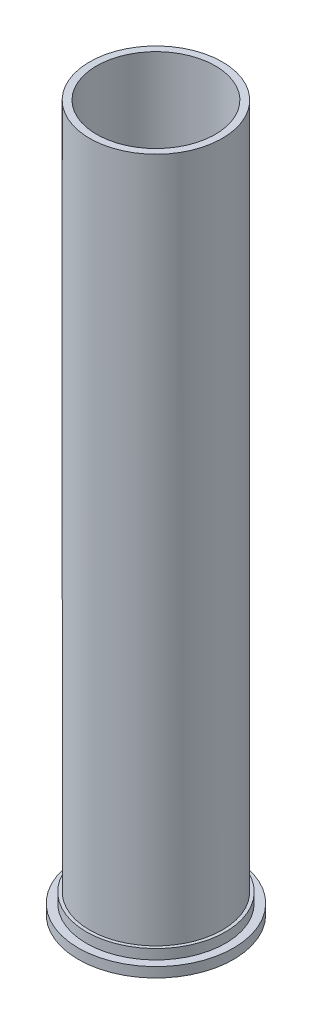
from build123d import *

# Parameters (mm, degrees)
SKETCH1_W           = 1.5
SKETCH1_H           = 152.24
SKETCH2_R           = 16.75
BOSS_EXTRUDE1_DEPTH = 2.14
SKETCH4_R           = 15
BOSS_EXTRUDE2_DEPTH = 2.14


with BuildPart() as part:
    # Sketch1 → Revolve1 (revolve)
    with BuildSketch(Plane.XY):
        with Locations((13.565, 76.12)):
            Rectangle(SKETCH1_W, SKETCH1_H)
    revolve(axis=Axis((0, 0, 0), (0, 1, 0)))

    # Sketch2 → Boss-Extrude1 (add)
    with BuildSketch(Plane(origin=(0, 0, 0), x_dir=(1, 0, 0), z_dir=(0, 1, 0))):
        Circle(SKETCH2_R)
    extrude(amount=BOSS_EXTRUDE1_DEPTH)

    # Sketch4 → Boss-Extrude2 (add)
    with BuildSketch(Plane(origin=(0, 2.14, 0), x_dir=(1, 0, 0), z_dir=(0, 1, 0))):
        Circle(SKETCH4_R)
    extrude(amount=BOSS_EXTRUDE2_DEPTH)


solid = part.part
